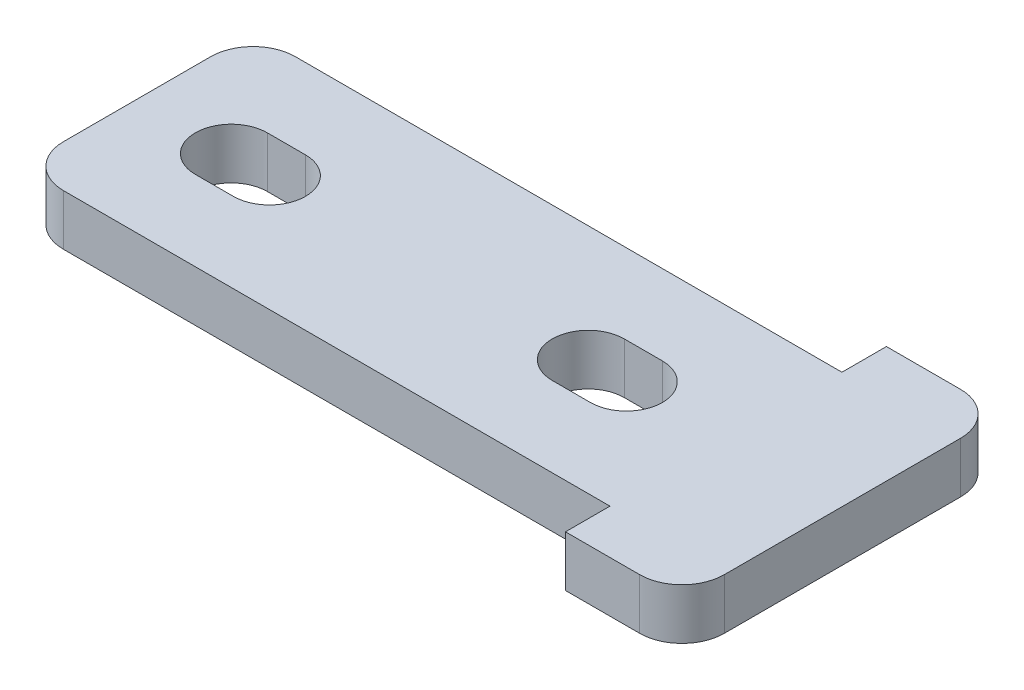
from build123d import *

# Parameters (mm, degrees)
BOSS_EXTRUDE1_DEPTH = 2.4
FILLET1_R           = 2


with BuildPart() as part:
    # Sketch1 → Boss-Extrude1 (new body)
    with BuildSketch(Plane(origin=(0, 0, 0), x_dir=(1, 0, 0), z_dir=(0, 1, 0))):
        Polygon((27.8, 2.1), (27.8, 0), (33.3, 0), (33.3, 15.15), (27.8, 15.15), (27.8, 13.05), (0, 13.05), (0, 2.1), align=None)
        with BuildLine():
            ThreePointArc((4.45, 5.875), (2.75, 7.575), (4.45, 9.275))
            Line((4.45, 9.275), (6.25, 9.275))
            ThreePointArc((6.25, 9.275), (7.95, 7.575), (6.25, 5.875))
            Line((6.25, 5.875), (4.45, 5.875))
        make_face(mode=Mode.SUBTRACT)
        with BuildLine():
            ThreePointArc((23.1, 9.275), (24.8, 7.575), (23.1, 5.875))
            Line((23.1, 5.875), (21.3, 5.875))
            ThreePointArc((21.3, 5.875), (19.6, 7.575), (21.3, 9.275))
            Line((21.3, 9.275), (23.1, 9.275))
        make_face(mode=Mode.SUBTRACT)
    extrude(amount=-BOSS_EXTRUDE1_DEPTH)

    # Fillet1
    fillet1_edges = [part.edges().sort_by_distance(p)[0] for p in [
        (33.3, -1.2, -15.15),
        (33.3, -1.2, 0),
        (0, -1.2, -2.1),
        (0, -1.2, -13.05),
    ]]
    fillet(fillet1_edges, radius=FILLET1_R)


solid = part.part
